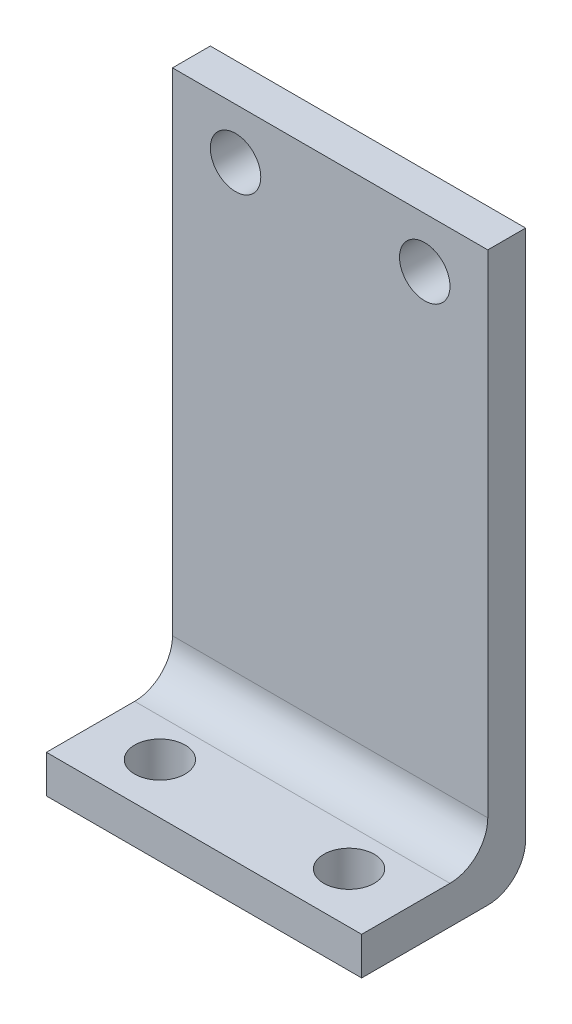
from build123d import *

# Parameters (mm, degrees)
SKETCH1_W           = 25
SKETCH1_H           = 45
SKETCH1_R           = 2
BOSS_EXTRUDE1_DEPTH = 3
BOSS_EXTRUDE2_START = -3
SKETCH1_3_W         = 25
SKETCH1_3_H         = 3
BOSS_EXTRUDE2_DEPTH = 13
FILLET1_R           = 3
SKETCH2_R           = 2
CUT_EXTRUDE1_DEPTH  = 46


with BuildPart() as part:
    # Sketch1 → Boss-Extrude1 (new body)
    with BuildSketch(Plane.XY):
        with Locations((12.5, 22.5)):
            Rectangle(SKETCH1_W, SKETCH1_H)
        with Locations((20, 41)):
            Circle(SKETCH1_R, mode=Mode.SUBTRACT)
        with Locations((5, 41)):
            Circle(SKETCH1_R, mode=Mode.SUBTRACT)
    extrude(amount=-BOSS_EXTRUDE1_DEPTH)

    # Sketch1_3 → Boss-Extrude2 (add)
    with BuildSketch(Plane.XY.offset(BOSS_EXTRUDE2_START)):
        with Locations((12.5, 1.5)):
            Rectangle(SKETCH1_3_W, SKETCH1_3_H)
    extrude(amount=BOSS_EXTRUDE2_DEPTH)

    # Fillet1
    fillet1_edges = [part.edges().sort_by_distance(p)[0] for p in [
        (12.5, 3, 0),
        (12.5, 0, -3),
    ]]
    fillet(fillet1_edges, radius=FILLET1_R)

    # Sketch2 → Cut-Extrude1 (cut, through all)
    with BuildSketch(Plane(origin=(0, 0, 0), x_dir=(-1, 0, 0), z_dir=(0, -1, 0))):
        with Locations((-5, -6)):
            Circle(SKETCH2_R)
        with Locations((-20, -6)):
            Circle(SKETCH2_R)
    extrude(amount=-CUT_EXTRUDE1_DEPTH, mode=Mode.SUBTRACT)


solid = part.part
